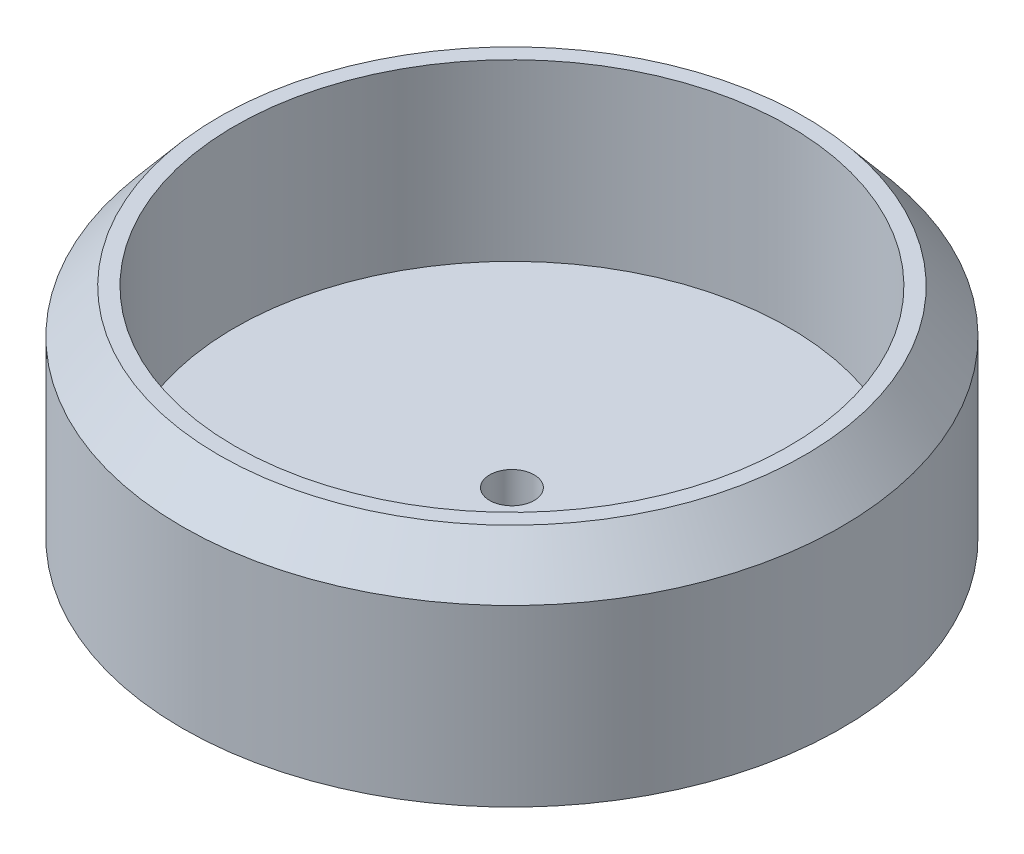
from build123d import *

# Parameters (mm, degrees)
SKETCH1_R               = 37.75
BOSS_EXTRUDE1_DEPTH     = 5
SKETCH2_R               = 37.75
SKETCH2_R_2             = 31.7505
BOSS_EXTRUDE2_DEPTH     = 20
CHAMFER1_SIZE           = 5
CHAMFER1_SIZE2          = 4.195498156
SKETCH3_R               = 2.55
CUT_EXTRUDE1_DEPTH      = 1
CUT_EXTRUDE1_DEPTH_BACK = 26


with BuildPart() as part:
    # Sketch1 → Boss-Extrude1 (new body)
    with BuildSketch(Plane(origin=(0, 0, 0), x_dir=(1, 0, 0), z_dir=(0, 1, 0))):
        Circle(SKETCH1_R)
    extrude(amount=BOSS_EXTRUDE1_DEPTH)

    # Sketch2 → Boss-Extrude2 (add)
    with BuildSketch(Plane(origin=(0, 5, 0), x_dir=(1, 0, 0), z_dir=(0, 1, 0))):
        Circle(SKETCH2_R)
        Circle(SKETCH2_R_2, mode=Mode.SUBTRACT)
    extrude(amount=BOSS_EXTRUDE2_DEPTH)

    # Chamfer1
    chamfer1_edges = [part.edges().sort_by_distance(p)[0] for p in [
        (-37.75, 25, 0),
    ]]
    chamfer1_side = [part.faces().sort_by_distance(p)[0] for p in [
        (-37.75, 12.5, 0),
    ]]
    chamfer(chamfer1_edges, length=CHAMFER1_SIZE, length2=CHAMFER1_SIZE2, reference=chamfer1_side[0])

    # Sketch3 → Cut-Extrude1 (cut, two sides)
    with BuildSketch(Plane.XZ) as cut_extrude1_sk:
        Circle(SKETCH3_R)
    extrude(amount=CUT_EXTRUDE1_DEPTH, mode=Mode.SUBTRACT)
    extrude(cut_extrude1_sk.sketch, amount=-CUT_EXTRUDE1_DEPTH_BACK, mode=Mode.SUBTRACT)


solid = part.part
